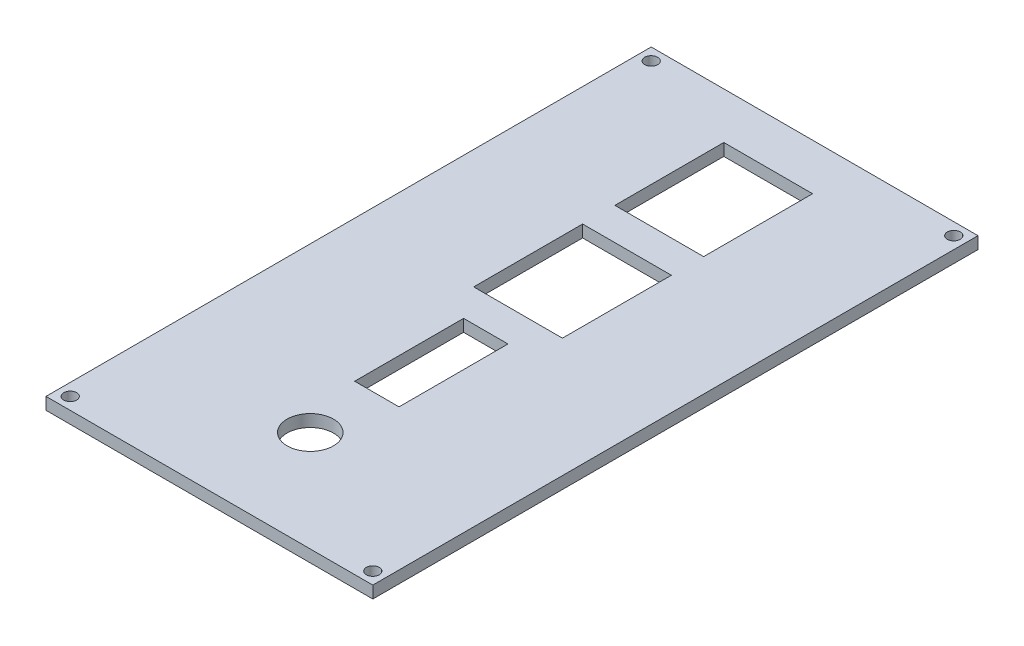
from build123d import *

# Parameters (mm, degrees)
SKETCH1_W            = 81
SKETCH1_H            = 150
BOSS_EXTRUDE1_DEPTH  = 3
M3_CLEARANCE_HOLE1_D = 3.2
SKETCH9_R            = 5.75
SKETCH9_W            = 22
SKETCH9_H            = 27
SKETCH9_W_2          = 11
CUT_EXTRUDE1_DEPTH   = 4


with BuildPart() as part:
    # Sketch1 → Boss-Extrude1 (new body)
    with BuildSketch(Plane(origin=(0, 0, 0), x_dir=(1, 0, 0), z_dir=(0, 1, 0))):
        with Locations((40.5, 75)):
            Rectangle(SKETCH1_W, SKETCH1_H)
    extrude(amount=BOSS_EXTRUDE1_DEPTH)

    # M3 Clearance Hole1 (through all)
    with Locations(Plane(origin=(3, 3, -147), x_dir=(0, 0, 1), z_dir=(0, 1, 0))):
        with Locations((0, 0), (0, 75), (144, 75), (144, 0)):
            Hole(M3_CLEARANCE_HOLE1_D / 2)

    # Sketch9 → Cut-Extrude1 (cut, through all)
    with BuildSketch(Plane(origin=(0, 3, 0), x_dir=(1, 0, 0), z_dir=(0, 1, 0))):
        with Locations((40.5, 25)):
            Circle(SKETCH9_R)
        with Locations((40.5, 125)):
            Rectangle(SKETCH9_W, SKETCH9_H)
        with Locations((40.5, 90)):
            Rectangle(SKETCH9_W, SKETCH9_H)
        with Locations((40.5, 55)):
            Rectangle(SKETCH9_W_2, SKETCH9_H)
    extrude(amount=-CUT_EXTRUDE1_DEPTH, mode=Mode.SUBTRACT)


solid = part.part
